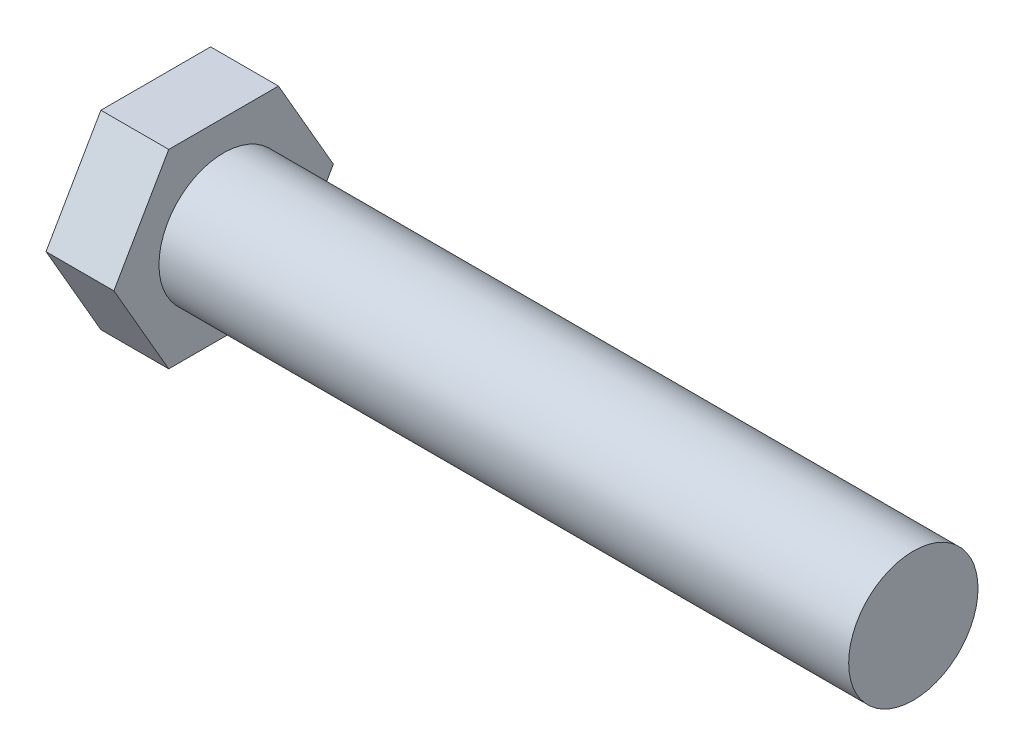
from build123d import *

# Parameters (mm, degrees)
SKETCH1_R           = 4.7625
BOSS_EXTRUDE1_DEPTH = 50.8
BOSS_EXTRUDE2_DEPTH = 5


with BuildPart() as part:
    # Sketch1 → Boss-Extrude1 (new body)
    with BuildSketch(Plane(origin=(0, 0, 0), x_dir=(0, 0, -1), z_dir=(1, 0, 0))):
        Circle(SKETCH1_R)
    extrude(amount=BOSS_EXTRUDE1_DEPTH)

    # Sketch2 → Boss-Extrude2 (add)
    with BuildSketch(Plane.ZY):
        Polygon((8.082903769, 0), (4.041451884, 7), (-4.041451884, 7), (-8.082903769, 0), (-4.041451884, -7), (4.041451884, -7), align=None)
    extrude(amount=BOSS_EXTRUDE2_DEPTH)


solid = part.part
